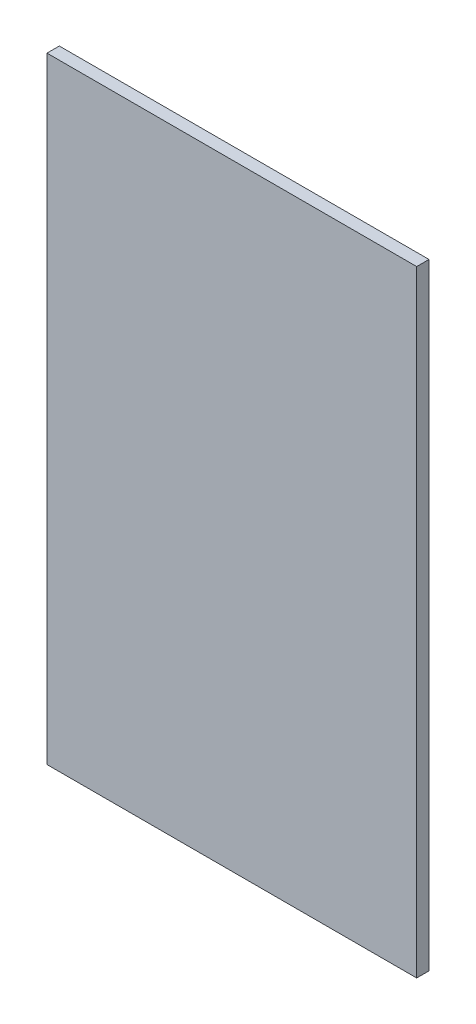
from build123d import *

# Parameters (mm, degrees)
SKETCH1_W      = 300
SKETCH1_H      = 500
EXTRUDE1_DEPTH = 10


with BuildPart() as part:
    # Sketch1 → Extrude1 (new body)
    with BuildSketch(Plane.XY):
        with Locations((150, 250)):
            Rectangle(SKETCH1_W, SKETCH1_H)
    extrude(amount=EXTRUDE1_DEPTH)


solid = part.part
